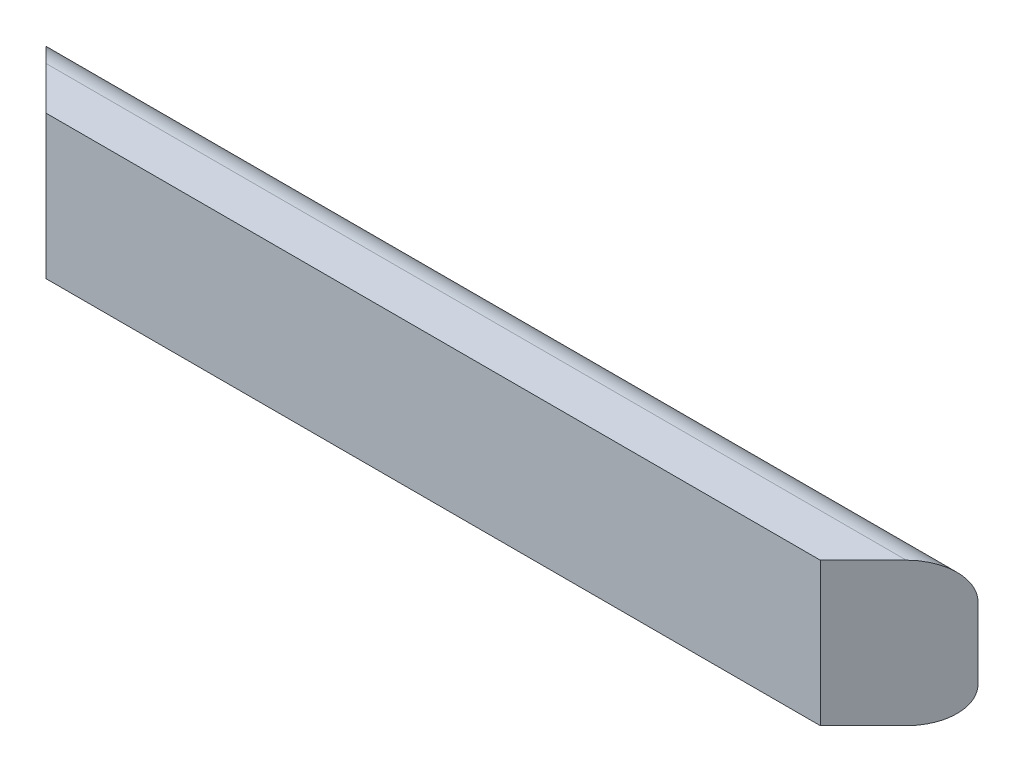
from build123d import *

# Parameters (mm, degrees)
BOSS_EXTRUDE1_DEPTH      = 412.75
BOSS_EXTRUDE1_DEPTH_BACK = 412.75
CUT_EXTRUDE1_DEPTH       = 438.459238101
BOSS_EXTRUDE2_DEPTH      = 0.254


with BuildPart() as part:
    # Sketch1 → Boss-Extrude1 (new, two sides: drawn at the far end of the back side and taken through both)
    with BuildSketch(Plane(origin=(0, 0, 0), x_dir=(0, 0, -1), z_dir=(1, 0, 0)).offset(-BOSS_EXTRUDE1_DEPTH_BACK)):
        with BuildLine():
            Line((6.35, 127), (38.1, 127))
            ThreePointArc((38.1, 127), (60.550640303, 117.700640303), (69.85, 95.25))
            Line((69.85, 95.25), (69.85, 31.75))
            ThreePointArc((69.85, 31.75), (60.550640303, 9.299359697), (38.1, 0))
            Line((38.1, 0), (6.35, 0))
            Line((6.35, 0), (0, 0))
            Line((0, 0), (0, 127))
            Line((0, 127), (6.35, 127))
        make_face()
    extrude(amount=BOSS_EXTRUDE1_DEPTH + BOSS_EXTRUDE1_DEPTH_BACK)

    # Sketch2 → Cut-Extrude1 (cut, through all)
    with BuildSketch(Plane(origin=(0, 127, 0), x_dir=(1, 0, 0), z_dir=(0, 1, 0))):
        Polygon((412.75, 69.85), (342.9, 0), (412.75, 0), align=None)
        Polygon((-412.75, 69.85), (-342.9, 0), (-412.75, 0), align=None)
    extrude(amount=-CUT_EXTRUDE1_DEPTH, mode=Mode.SUBTRACT)

    # Sketch3 → Boss-Extrude2 (add)
    # profile 1 of 4: a face of its own
    with BuildSketch(Plane(origin=(0, 0, -69.85), x_dir=(-1, 0, 0), z_dir=(0, 0, -1))):
        with BuildLine():
            Line((-141.487283737, 49.988561174), (-129.139597752, 51.506297576))
            add(Edge.make_bspline(
                [(-129.139597752, 51.506297576), (-129.032962671, 50.747064564), (-128.830554263, 49.305933343), (-128.199436765, 47.311224862), (-127.375544429, 45.575399002), (-126.284752313, 44.15314528), (-125.023613015, 43.021998512), (-123.617151139, 42.214884132), (-122.078088821, 41.705902447), (-121.006107171, 41.654466058), (-120.457631044, 41.628148788)],
                knots=[0, 0, 0, 0, 1.26631894, 2.403651751, 3.447242243, 4.428907923, 5.348362865, 6.231623936, 7.095215805, 8, 8, 8, 8], degree=3))
            add(Edge.make_bspline(
                [(-120.457631044, 41.628148788), (-120.161330426, 41.634511687), (-119.574405191, 41.647115596), (-118.711610093, 41.779355342), (-117.882599365, 41.996726001), (-117.095552411, 42.309506181), (-116.34671202, 42.698139812), (-115.626217183, 43.160949602), (-114.964334496, 43.738979779), (-114.318123207, 44.37140603), (-113.74466798, 45.091318713), (-113.239522217, 45.872393773), (-112.796104536, 46.706884108), (-112.452410387, 47.616306001), (-112.18337499, 48.58096015), (-111.991040418, 49.605033933), (-111.873985761, 50.684667137), (-111.859983423, 51.424537153), (-111.852837373, 51.802127553)],
                knots=[0, 0, 0, 0, 0.951760839, 1.885289532, 2.797832748, 3.70117291, 4.60103766, 5.506897018, 6.445598779, 7.420035506, 8.410036365, 9.396193293, 10.407074535, 11.440988179, 12.514285005, 13.622404236, 14.786601276, 16, 16, 16, 16], degree=3))
            add(Edge.make_bspline(
                [(-111.852837373, 51.802127553), (-111.879604371, 52.502912818), (-111.930665339, 53.839737143), (-112.325229706, 55.7363289), (-113.009474812, 57.403510016), (-113.968135732, 58.811372072), (-115.107297702, 59.943891395), (-116.38339385, 60.795183755), (-117.808484904, 61.284244815), (-118.799184723, 61.350799485), (-119.300035483, 61.384446364)],
                knots=[0, 0, 0, 0, 1.241512862, 2.368321189, 3.414110003, 4.41529485, 5.36642979, 6.245396713, 7.112955941, 8, 8, 8, 8], degree=3))
            add(Edge.make_bspline(
                [(-119.300035483, 61.384446364), (-119.656610092, 61.375322265), (-120.412510639, 61.355980138), (-121.58827301, 61.155013218), (-122.870446973, 60.877669799), (-123.74350999, 60.610883817), (-124.200523358, 60.471232088)],
                knots=[0, 0, 0, 0, 0.854525515, 1.811503923, 2.854410343, 4, 4, 4, 4], degree=3))
            Line((-124.200523358, 60.471232088), (-123.042927797, 70.439416087))
            add(Edge.make_bspline(
                [(-123.042927797, 70.439416087), (-122.699793823, 70.433529916), (-122.033943987, 70.422107829), (-121.061603486, 70.502723798), (-120.151462794, 70.649910548), (-119.305645566, 70.888720241), (-118.523364253, 71.178445171), (-117.797777169, 71.542462959), (-117.146635388, 71.995464307), (-116.353828061, 72.679267448), (-115.542714487, 73.703905506), (-114.809416499, 75.108914451), (-114.400837558, 76.710921704), (-114.349142899, 77.832955884), (-114.32237457, 78.413963285)],
                knots=[0, 0, 0, 0, 0.916749589, 1.778948191, 2.604102396, 3.376994206, 4.124053722, 4.831292757, 5.54010828, 6.238660037, 7.62386988, 9.002523041, 10.447858069, 12, 12, 12, 12], degree=3))
            add(Edge.make_bspline(
                [(-114.32237457, 78.413963285), (-114.340421784, 78.908707793), (-114.375026012, 79.857344611), (-114.685449372, 81.207210903), (-115.215277515, 82.398975794), (-115.956386082, 83.411952531), (-116.865477663, 84.234520651), (-117.928062929, 84.842338565), (-119.145149606, 85.196777383), (-120.000810014, 85.236190038), (-120.444768871, 85.256639269)],
                knots=[0, 0, 0, 0, 1.146968804, 2.199229744, 3.192297141, 4.153502289, 5.090509175, 6.0173182, 6.971286811, 8, 8, 8, 8], degree=3))
            add(Edge.make_bspline(
                [(-120.444768871, 85.256639269), (-120.889846441, 85.23463774), (-121.764714725, 85.191390357), (-123.016587755, 84.763605166), (-124.171507752, 84.101718979), (-125.190641675, 83.153836406), (-126.073947139, 81.974913825), (-126.758445098, 80.537127716), (-127.240501283, 78.863003816), (-127.406174904, 77.658066607), (-127.493239621, 77.024848612)],
                knots=[0, 0, 0, 0, 0.889956214, 1.749345552, 2.62404616, 3.543272128, 4.520224035, 5.562553653, 6.719074424, 8, 8, 8, 8], degree=3))
            Line((-127.493239621, 77.024848612), (-139.840925606, 78.87700151))
            add(Edge.make_bspline(
                [(-139.840925606, 78.87700151), (-139.637325698, 79.819720317), (-139.247589866, 81.624295295), (-138.451300452, 84.152640803), (-137.51697339, 86.384586473), (-136.425350386, 88.345144228), (-135.132300003, 90.068833733), (-133.597053466, 91.56499453), (-131.842580673, 92.877041648), (-129.872231734, 93.976422082), (-127.72989182, 94.857582736), (-125.449924009, 95.509752612), (-123.038143208, 95.883504452), (-121.389271871, 95.93280399), (-120.547666254, 95.957967122)],
                knots=[0, 0, 0, 0, 1.220808349, 2.336900656, 3.3513467, 4.279992853, 5.171472476, 6.069835959, 6.985198729, 7.938095762, 8.919113729, 9.91246339, 10.934493858, 12, 12, 12, 12], degree=3))
            add(Edge.make_bspline(
                [(-120.547666254, 95.957967122), (-119.826495707, 95.941556837), (-118.417458275, 95.909494092), (-116.362747759, 95.633600563), (-114.418641852, 95.185408458), (-112.582430461, 94.55140964), (-110.845601518, 93.744182635), (-109.237149801, 92.728555989), (-107.723332756, 91.556250599), (-106.826681472, 90.643909975), (-106.373551717, 90.18285149)],
                knots=[0, 0, 0, 0, 1.096978699, 2.143298912, 3.148181587, 4.128190255, 5.094201205, 6.055441919, 7.017302331, 8, 8, 8, 8], degree=3))
            add(Edge.make_bspline(
                [(-106.373551717, 90.18285149), (-106.023537684, 89.789960912), (-105.332223658, 89.013961265), (-104.434645502, 87.76983024), (-103.683420883, 86.477065821), (-103.046188148, 85.162642075), (-102.572302428, 83.796078916), (-102.21901684, 82.398827932), (-102.009177681, 80.958508612), (-101.986217703, 79.983817154), (-101.974688585, 79.494385809)],
                knots=[0, 0, 0, 0, 1.065582675, 2.104636323, 3.101288825, 4.092056841, 5.059084899, 6.026073946, 7.008813224, 8, 8, 8, 8], degree=3))
            add(Edge.make_bspline(
                [(-101.974688585, 79.494385809), (-101.999837567, 78.805967701), (-102.049410836, 77.448969012), (-102.504305984, 75.474938782), (-103.235446067, 73.608860109), (-104.24640348, 71.843604558), (-105.564457117, 70.195553035), (-107.18702939, 68.679534469), (-109.066442264, 67.237696856), (-110.47902046, 66.423262632), (-111.209728728, 66.001966436)],
                knots=[0, 0, 0, 0, 0.957571776, 1.887550067, 2.804499428, 3.740591036, 4.709432777, 5.731457079, 6.826512349, 8, 8, 8, 8], degree=3))
            add(Edge.make_bspline(
                [(-111.209728728, 66.001966436), (-110.774920169, 65.897167744), (-109.916890308, 65.690363151), (-108.677362831, 65.268754117), (-107.51653992, 64.727943501), (-106.405990923, 64.133720127), (-105.373275352, 63.429091991), (-104.398375528, 62.648317715), (-103.518575507, 61.746303626), (-102.675530041, 60.793323049), (-101.938600577, 59.747465525), (-101.272737218, 58.65913874), (-100.737902273, 57.501788739), (-100.280457077, 56.30517302), (-99.939604466, 55.04995027), (-99.672693466, 53.745511556), (-99.538908832, 52.383737677), (-99.516490646, 51.459364418), (-99.505151388, 50.99181066)],
                knots=[0, 0, 0, 0, 1.037381978, 2.047118658, 3.030848314, 4.005687143, 4.965748246, 5.927353932, 6.897971669, 7.885165084, 8.876109723, 9.862099733, 10.840989857, 11.829385213, 12.830906716, 13.855042526, 14.915067134, 16, 16, 16, 16], degree=3))
            add(Edge.make_bspline(
                [(-99.505151388, 50.99181066), (-99.51956021, 50.308923997), (-99.547976345, 48.962179679), (-99.860092867, 46.985641935), (-100.33429342, 45.08605931), (-100.987783847, 43.255757597), (-101.861740077, 41.517130623), (-102.906804937, 39.845787022), (-104.151443825, 38.258375189), (-105.570731672, 36.76692481), (-107.12155314, 35.401826739), (-108.787905722, 34.20277421), (-110.545100916, 33.187927397), (-112.403207023, 32.358101162), (-114.346066599, 31.712439867), (-116.390404873, 31.268680945), (-118.519638929, 30.972625251), (-119.976421673, 30.942228997), (-120.714874502, 30.926820934)],
                knots=[0, 0, 0, 0, 1.006520189, 1.984993146, 2.943645202, 3.891894145, 4.845023195, 5.808336607, 6.795092628, 7.815033679, 8.841288157, 9.838185905, 10.83832808, 11.829129029, 12.835072876, 13.85234392, 14.911338897, 16, 16, 16, 16], degree=3))
            add(Edge.make_bspline(
                [(-120.714874502, 30.926820934), (-121.414664815, 30.938552975), (-122.789217771, 30.961597466), (-124.80144877, 31.234596831), (-126.728716817, 31.636211012), (-128.559772747, 32.223729356), (-130.310566514, 32.947387314), (-131.948052536, 33.880254279), (-133.514382161, 34.940534945), (-134.958381911, 36.182569084), (-136.300989349, 37.536259204), (-137.480309186, 39.024940262), (-138.531240362, 40.601098684), (-139.435141753, 42.278708256), (-140.184438628, 44.062128348), (-140.767869909, 45.946755571), (-141.23316759, 47.926818682), (-141.401411105, 49.29184333), (-141.487283737, 49.988561174)],
                knots=[0, 0, 0, 0, 1.077528213, 2.11651914, 3.123276654, 4.10732375, 5.075386463, 6.036572488, 7.005896639, 7.98540975, 8.966414275, 9.939311093, 10.906719916, 11.882103104, 12.870994428, 13.882228509, 14.919075059, 16, 16, 16, 16], degree=3))
        make_face()
    # profile 2 of 4: a face of its own
    with BuildSketch(Plane(origin=(0, 0, -69.85), x_dir=(-1, 0, 0), z_dir=(0, 0, -1))):
        with BuildLine():
            Line((-62.462093433, 50.117182903), (-51.760765579, 51.506297576))
            add(Edge.make_bspline(
                [(-51.760765579, 51.506297576), (-51.642380093, 50.780568), (-51.41440933, 49.383056103), (-50.706719158, 47.432022129), (-49.721163459, 45.713239113), (-48.454544685, 44.265955932), (-47.012973527, 43.088892136), (-45.420400197, 42.249747655), (-43.725063478, 41.721422366), (-42.550922605, 41.659383078), (-41.959789828, 41.628148788)],
                knots=[0, 0, 0, 0, 1.154848647, 2.223851388, 3.245409892, 4.254330626, 5.232966172, 6.156270698, 7.071756339, 8, 8, 8, 8], degree=3))
            add(Edge.make_bspline(
                [(-41.959789828, 41.628148788), (-41.616370664, 41.634182289), (-40.944122367, 41.645992961), (-39.953467627, 41.780059227), (-39.007120064, 41.997870012), (-38.096125975, 42.293479709), (-37.229973938, 42.682269208), (-36.407893848, 43.158045805), (-35.626813523, 43.721477925), (-34.8827795, 44.358572654), (-34.195286077, 45.085965129), (-33.620713178, 45.923247733), (-33.111714207, 46.827631979), (-32.697063985, 47.823687055), (-32.398158929, 48.914903645), (-32.160358427, 50.082600806), (-32.039139227, 51.340876348), (-32.016273212, 52.204936271), (-32.004468003, 52.651030964)],
                knots=[0, 0, 0, 0, 0.981268084, 1.920847364, 2.851509818, 3.754644372, 4.654445699, 5.560569672, 6.465366234, 7.403985617, 8.358004942, 9.316972086, 10.299158387, 11.321223707, 12.392031981, 13.529051644, 14.724304971, 16, 16, 16, 16], degree=3))
            add(Edge.make_bspline(
                [(-32.004468003, 52.651030964), (-32.011143045, 53.071527767), (-32.024043665, 53.884207159), (-32.14373122, 55.061642393), (-32.327450959, 56.161966499), (-32.619720064, 57.177134497), (-32.953514389, 58.126018474), (-33.403553287, 58.974986748), (-33.897360682, 59.760920289), (-34.499236907, 60.441413996), (-35.155036013, 61.04267379), (-35.85345981, 61.578386386), (-36.602348538, 62.02538699), (-37.394245331, 62.409044411), (-38.242877677, 62.688498613), (-39.141362088, 62.874418229), (-40.077617441, 63.013987895), (-40.72018881, 63.025139942), (-41.046575552, 63.030804496)],
                knots=[0, 0, 0, 0, 1.29221626, 2.497420946, 3.635005972, 4.715822244, 5.741640361, 6.720139245, 7.663294346, 8.588224307, 9.502291809, 10.395891443, 11.288713187, 12.178904539, 13.095818132, 14.026458458, 14.997562253, 16, 16, 16, 16], degree=3))
            add(Edge.make_bspline(
                [(-41.046575552, 63.030804496), (-41.45922931, 63.016010253), (-42.282480026, 62.986495507), (-43.497746027, 62.746569399), (-44.680614197, 62.355968027), (-45.829855089, 61.812223729), (-46.94242819, 61.110991483), (-48.013516609, 60.24994579), (-49.061506146, 59.243900895), (-49.705242128, 58.483757088), (-50.03723441, 58.091730101)],
                knots=[0, 0, 0, 0, 0.931687088, 1.85873035, 2.786835662, 3.740075265, 4.723687035, 5.750832598, 6.840042753, 8, 8, 8, 8], degree=3))
            Line((-50.03723441, 58.091730101), (-60.815735301, 59.609466504))
            Line((-60.815735301, 59.609466504), (-53.40712371, 95.134788057))
            Line((-53.40712371, 95.134788057), (-22.126319215, 95.134788057))
            Line((-22.126319215, 95.134788057), (-22.126319215, 82.787102072))
            Line((-22.126319215, 82.787102072), (-43.503250577, 82.787102072))
            Line((-43.503250577, 82.787102072), (-46.024236465, 71.326906017))
            add(Edge.make_bspline(
                [(-46.024236465, 71.326906017), (-45.381816964, 71.697561885), (-44.130764923, 72.419379607), (-42.133452016, 73.162424748), (-40.125878911, 73.639323084), (-38.77255902, 73.701356019), (-38.101137958, 73.732132349)],
                knots=[0, 0, 0, 0, 1.060051984, 2.064352337, 3.039669322, 4, 4, 4, 4], degree=3))
            add(Edge.make_bspline(
                [(-38.101137958, 73.732132349), (-37.469945095, 73.715146712), (-36.223094674, 73.681593499), (-34.394484466, 73.406300074), (-32.640499622, 72.952588242), (-30.955217357, 72.321200736), (-29.350691977, 71.493616454), (-27.813091414, 70.49335495), (-26.36461393, 69.303058942), (-24.989696213, 67.957093414), (-23.73586773, 66.467944448), (-22.653087096, 64.844102956), (-21.717878139, 63.126012929), (-20.956507189, 61.294691655), (-20.383173048, 59.347591366), (-19.953801197, 57.301478184), (-19.713270125, 55.1434317), (-19.675867936, 53.671994501), (-19.656782018, 52.921136595)],
                knots=[0, 0, 0, 0, 0.974409932, 1.924837087, 2.848242317, 3.768103797, 4.697919751, 5.630842317, 6.595644344, 7.588240789, 8.59876155, 9.595918743, 10.597287627, 11.615415169, 12.652315553, 13.727511434, 14.840374562, 16, 16, 16, 16], degree=3))
            add(Edge.make_bspline(
                [(-19.656782018, 52.921136595), (-19.674008435, 52.290478014), (-19.70819943, 51.038746756), (-19.908190569, 49.186441287), (-20.281535625, 47.38868729), (-20.757123097, 45.635357275), (-21.414391177, 43.941141258), (-22.194366108, 42.294994206), (-23.126749606, 40.699872055), (-23.846097598, 39.693450362), (-24.209991225, 39.184335937)],
                knots=[0, 0, 0, 0, 1.027524957, 2.039431707, 3.02972907, 4.015954419, 4.995255842, 5.985553205, 6.980960039, 8, 8, 8, 8], degree=3))
            add(Edge.make_bspline(
                [(-24.209991225, 39.184335937), (-24.740475206, 38.528772068), (-25.784529389, 37.238546115), (-27.571811387, 35.542219666), (-29.515699496, 34.11760187), (-31.610928766, 32.947630365), (-33.855267088, 32.029523153), (-36.258840659, 31.391212776), (-38.804026141, 30.996298985), (-40.552052993, 30.950317625), (-41.445302912, 30.926820934)],
                knots=[0, 0, 0, 0, 1.018121711, 2.003781959, 2.967346956, 3.92281574, 4.896313303, 5.889026666, 6.921282725, 8, 8, 8, 8], degree=3))
            add(Edge.make_bspline(
                [(-41.445302912, 30.926820934), (-42.166315783, 30.939844326), (-43.574132764, 30.965273209), (-45.635849187, 31.216745865), (-47.589676133, 31.625295782), (-49.447940052, 32.192240734), (-51.199607305, 32.928566139), (-52.858287962, 33.817543442), (-54.410162381, 34.878876743), (-55.848084307, 36.104548031), (-57.16849389, 37.459270233), (-58.346241116, 38.941581824), (-59.394127645, 40.526691501), (-60.292161634, 42.230616097), (-61.057498838, 44.041405853), (-61.66689253, 45.968341085), (-62.168636561, 47.998571276), (-62.363191729, 49.403162141), (-62.462093433, 50.117182903)],
                knots=[0, 0, 0, 0, 1.098912142, 2.145685936, 3.161086862, 4.139124218, 5.10307886, 6.053641493, 7.003731987, 7.963777669, 8.929946266, 9.883471279, 10.846206077, 11.822909928, 12.81603559, 13.839338588, 14.901632394, 16, 16, 16, 16], degree=3))
        make_face()
    # profile 3 of 4: a face of its own
    with BuildSketch(Plane(origin=(0, 0, -69.85), x_dir=(-1, 0, 0), z_dir=(0, 0, -1))):
        with BuildLine():
            Line((18.209455003, 47.673370052), (30.557140988, 49.036760379))
            add(Edge.make_bspline(
                [(30.557140988, 49.036760379), (30.637994326, 48.445590088), (30.790823737, 47.328156849), (31.279511065, 45.794795533), (31.892008924, 44.478581747), (32.724355074, 43.419388765), (33.717669119, 42.610927467), (34.855326057, 42.027551658), (36.141865973, 41.691510589), (37.046257906, 41.649795905), (37.515576528, 41.628148788)],
                knots=[0, 0, 0, 0, 1.261142327, 2.383817955, 3.394783384, 4.319218401, 5.209639591, 6.086630953, 7.00709008, 8, 8, 8, 8], degree=3))
            add(Edge.make_bspline(
                [(37.515576528, 41.628148788), (37.82108926, 41.635229881), (38.424869783, 41.649224147), (39.308127474, 41.846519093), (40.162847532, 42.123113217), (40.980220047, 42.527938781), (41.752430951, 43.048944096), (42.49862858, 43.674368665), (43.195924432, 44.424262543), (43.888543524, 45.285004598), (44.515475303, 46.342388481), (45.068777974, 47.624884025), (45.585382265, 49.132135662), (46.00974389, 50.882888201), (46.391709615, 52.862052998), (46.723999497, 55.075963918), (46.993591195, 57.525973704), (47.112747025, 59.240222456), (47.175068376, 60.136815593)],
                knots=[0, 0, 0, 0, 0.636702566, 1.258306339, 1.881198412, 2.509855161, 3.155497192, 3.822694, 4.538353708, 5.290656154, 6.125969777, 7.095962945, 8.203044623, 9.449504243, 10.854253673, 12.411741228, 14.12325476, 16, 16, 16, 16], degree=3))
            add(Edge.make_bspline(
                [(47.175068376, 60.136815593), (46.780053355, 59.712840793), (46.001223909, 58.87691294), (44.71130418, 57.780208753), (43.337872185, 56.858167302), (41.887954292, 56.114969452), (40.376676573, 55.507774121), (38.779192363, 55.108371957), (37.117744626, 54.834342387), (35.981841775, 54.810896119), (35.406180172, 54.799013839)],
                knots=[0, 0, 0, 0, 1.041520616, 2.053509057, 3.037255372, 4.009786987, 4.979165048, 5.959157055, 6.965725879, 8, 8, 8, 8], degree=3))
            add(Edge.make_bspline(
                [(35.406180172, 54.799013839), (34.775120953, 54.817112148), (33.529147227, 54.852845749), (31.696139942, 55.112365051), (29.930031823, 55.554910939), (28.228003244, 56.168602168), (26.598658471, 56.982018065), (25.021221497, 57.94101676), (23.529542388, 59.101824931), (22.101856176, 60.398882812), (20.817953708, 61.859092441), (19.671322158, 63.424836719), (18.701040457, 65.104727317), (17.91842378, 66.896978746), (17.313156595, 68.790183052), (16.873104289, 70.782750287), (16.615986189, 72.885063224), (16.580967533, 74.323086545), (16.563096872, 75.056936158)],
                knots=[0, 0, 0, 0, 0.980269742, 1.935460739, 2.869230488, 3.804804075, 4.740187949, 5.694100724, 6.667990488, 7.67211685, 8.68661751, 9.683203946, 10.682901945, 11.694007529, 12.71565541, 13.766145059, 14.860022949, 16, 16, 16, 16], degree=3))
            add(Edge.make_bspline(
                [(16.563096872, 75.056936158), (16.579358734, 75.820994235), (16.611257549, 77.319749302), (16.891105872, 79.504796869), (17.318494615, 81.584769941), (17.956662218, 83.541236382), (18.750769394, 85.39520876), (19.737778026, 87.123436928), (20.884990955, 88.74995874), (22.225559796, 90.226408206), (23.682781679, 91.577954163), (25.254774523, 92.754100647), (26.932418562, 93.73702521), (28.700850793, 94.55387073), (30.573337417, 95.182961466), (32.537911021, 95.631263772), (34.596481997, 95.909234714), (36.001235713, 95.941500809), (36.718121808, 95.957967122)],
                knots=[0, 0, 0, 0, 1.1238417, 2.204496613, 3.236450213, 4.243990082, 5.227299393, 6.199188572, 7.167261658, 8.150145869, 9.127934804, 10.088143708, 11.032722787, 11.984040773, 12.949643861, 13.93368149, 14.945498424, 16, 16, 16, 16], degree=3))
            add(Edge.make_bspline(
                [(36.718121808, 95.957967122), (37.499663885, 95.936372471), (39.032175865, 95.894027903), (41.278242682, 95.541418364), (43.409401552, 94.941490996), (45.446828539, 94.136998461), (47.361156623, 93.065217924), (49.177290656, 91.771676373), (50.87096538, 90.229965387), (52.471833872, 88.470616193), (53.928355727, 86.437701122), (55.168440749, 84.088178395), (56.223269366, 81.444294852), (57.074690413, 78.500372651), (57.739976139, 75.2571666), (58.199148351, 71.714739072), (58.506399323, 67.872388312), (58.531967639, 65.209451336), (58.545229221, 63.828259215)],
                knots=[0, 0, 0, 0, 0.854852685, 1.67626545, 2.479841517, 3.273455256, 4.067207639, 4.874322592, 5.708061326, 6.568303409, 7.473035808, 8.43640186, 9.467839227, 10.582672616, 11.785182758, 13.086903962, 14.489057258, 16, 16, 16, 16], degree=3))
            add(Edge.make_bspline(
                [(58.545229221, 63.828259215), (58.52606159, 62.42569891), (58.489028928, 59.715893942), (58.190226205, 55.803928156), (57.717275991, 52.191835176), (57.021911158, 48.886068819), (56.149275747, 45.874742553), (55.051986756, 43.169327234), (53.774007676, 40.755869999), (52.277963864, 38.656593307), (50.633270353, 36.832085623), (48.865538969, 35.251440658), (46.97223569, 33.919424772), (44.969790555, 32.808349363), (42.828262634, 31.976311202), (40.577286451, 31.373516087), (38.210806803, 30.983032523), (36.59105741, 30.945785963), (35.766321013, 30.926820934)],
                knots=[0, 0, 0, 0, 1.487495966, 2.873904204, 4.158892752, 5.348685137, 6.453750751, 7.479786756, 8.440129076, 9.343583348, 10.206541379, 11.040779453, 11.853317241, 12.65721927, 13.463689683, 14.283322899, 15.125910407, 16, 16, 16, 16], degree=3))
            add(Edge.make_bspline(
                [(35.766321013, 30.926820934), (35.174171393, 30.939007153), (34.012346265, 30.962917083), (32.311353086, 31.155274015), (30.697323837, 31.489528146), (29.175630778, 31.956331344), (27.734397737, 32.530354721), (26.385860646, 33.258599195), (25.129668142, 34.124419027), (23.944430126, 35.101203305), (22.877760377, 36.233459151), (21.896551154, 37.483552941), (21.0163417, 38.863993528), (20.266693516, 40.386646363), (19.574694261, 42.016187918), (19.017259722, 43.788735665), (18.552348211, 45.684288067), (18.325771266, 46.998633491), (18.209455003, 47.673370052)],
                knots=[0, 0, 0, 0, 1.056675019, 2.073245589, 3.050223185, 3.994251036, 4.910773036, 5.814621688, 6.723026041, 7.630269412, 8.550362125, 9.493303905, 10.463425011, 11.466105649, 12.519144845, 13.620215273, 14.778306119, 16, 16, 16, 16], degree=3))
        make_face()
        with BuildLine():
            add(Edge.make_bspline(
                [(46.197543236, 74.748244008), (46.192995259, 75.156048345), (46.184156267, 75.94861615), (46.033839982, 77.096390923), (45.815742371, 78.171216494), (45.526890624, 79.185016488), (45.123602986, 80.121029748), (44.645261082, 80.993995513), (44.080043896, 81.796913755), (43.209927358, 82.734897139), (42.028819488, 83.744543753), (40.446606524, 84.62152998), (38.74720594, 85.168334822), (37.571066842, 85.226950878), (36.975365266, 85.256639269)],
                knots=[0, 0, 0, 0, 0.937516427, 1.822063352, 2.657744432, 3.45986214, 4.242145632, 4.997087526, 5.746986504, 6.494090859, 7.936347984, 9.300605415, 10.632786197, 12, 12, 12, 12], degree=3))
            add(Edge.make_bspline(
                [(36.975365266, 85.256639269), (36.419313856, 85.23142671), (35.337020127, 85.1823532), (33.788021298, 84.74130182), (32.38478746, 84.025462088), (31.362675998, 83.19033878), (30.634271685, 82.393802965), (30.177740451, 81.680286507), (29.789011167, 80.884969938), (29.467172874, 80.001072357), (29.213222033, 79.028114768), (29.03316865, 77.960908116), (28.935156065, 76.808046526), (28.919070985, 76.008914616), (28.910782857, 75.59714742)],
                knots=[0, 0, 0, 0, 1.397188569, 2.719475933, 4.017809812, 5.337496372, 6.01771949, 6.727108146, 7.460709441, 8.242571956, 9.09066939, 9.98839818, 10.963485712, 12, 12, 12, 12], degree=3))
            add(Edge.make_bspline(
                [(28.910782857, 75.59714742), (28.917415948, 75.176645173), (28.93023549, 74.363955259), (29.050489251, 73.186593506), (29.230890108, 72.094168937), (29.523932708, 71.095211047), (29.868235556, 70.175499084), (30.284003604, 69.332237197), (30.811986655, 68.596575836), (31.574683025, 67.724000391), (32.690543429, 66.835776981), (34.203521379, 66.061288394), (35.874923032, 65.582484293), (37.045062605, 65.528157919), (37.644198257, 65.500341693)],
                knots=[0, 0, 0, 0, 1.000122719, 1.932902026, 2.813346472, 3.630219284, 4.405058741, 5.14865055, 5.858963796, 6.55275156, 7.902081098, 9.220520156, 10.576848858, 12, 12, 12, 12], degree=3))
            add(Edge.make_bspline(
                [(37.644198257, 65.500341693), (38.226442431, 65.523155771), (39.36254862, 65.56767183), (40.978917558, 66.043138479), (42.462749954, 66.772451151), (43.548341231, 67.63319606), (44.3244001, 68.448453183), (44.823887088, 69.148575122), (45.25448236, 69.914845239), (45.59835283, 70.754069815), (45.868798685, 71.658960459), (46.05923458, 72.628038663), (46.177505057, 73.664886876), (46.190717154, 74.379194287), (46.197543236, 74.748244008)],
                knots=[0, 0, 0, 0, 1.470045212, 2.868431389, 4.227473852, 5.634383908, 6.348475288, 7.071419378, 7.805118666, 8.569021284, 9.362200428, 10.192314795, 11.06605236, 12, 12, 12, 12], degree=3))
        make_face(mode=Mode.SUBTRACT)
    # profile 4 of 4: a face of its own
    with BuildSketch(Plane(origin=(0, 0, -69.85), x_dir=(-1, 0, 0), z_dir=(0, 0, -1))):
        with BuildLine():
            Line((95.588287176, 82.787102072), (95.588287176, 95.134788057))
            Line((95.588287176, 95.134788057), (137.570419525, 95.134788057))
            Line((137.570419525, 95.134788057), (137.570419525, 86.079818334))
            add(Edge.make_bspline(
                [(137.570419525, 86.079818334), (137.132466652, 85.634215576), (136.232161359, 84.718184318), (134.942562083, 83.219008064), (133.633855634, 81.592138761), (132.333408388, 79.815654384), (131.000796599, 77.917617609), (129.694583854, 75.861644239), (128.369791871, 73.674406405), (126.586203006, 70.580554119), (124.501410169, 66.539027103), (122.295809638, 61.515202589), (120.416738972, 56.337091808), (119.130033868, 51.924959688), (118.260657453, 48.388642584), (117.692648976, 45.8028037), (117.214506378, 43.289733693), (116.825537694, 40.845015906), (116.535239413, 38.467535056), (116.30585427, 36.165556823), (116.192685302, 33.933467795), (116.175986043, 32.470381045), (116.167763818, 31.75)],
                knots=[0, 0, 0, 0, 0.628545797, 1.29210959, 1.98878689, 2.729126096, 3.507039704, 4.322017351, 5.179550397, 6.080149501, 7.915136253, 9.752312618, 11.597470118, 13.454141581, 14.373891568, 15.261584755, 16.117868869, 16.947726723, 17.752002974, 18.527724242, 19.275094557, 20, 20, 20, 20], degree=3))
            Line((116.167763818, 31.75), (103.820077833, 31.75))
            add(Edge.make_bspline(
                [(103.820077833, 31.75), (103.861365707, 32.843859978), (103.944400134, 35.043731895), (104.255069304, 38.345667879), (104.743008648, 41.659898836), (105.349062065, 44.994084575), (106.149203658, 48.340108138), (107.062410362, 51.71036421), (108.168622974, 55.086852328), (109.408657623, 58.463116455), (110.777590695, 61.80710167), (112.26953513, 65.077331726), (113.880634103, 68.253404415), (115.589935593, 71.3464789), (117.417324861, 74.34660455), (119.36417774, 77.250523525), (121.402878607, 80.079241784), (122.860574051, 81.884634059), (123.589237582, 82.787102072)],
                knots=[0, 0, 0, 0, 0.943249748, 1.896978291, 2.856365892, 3.829648507, 4.816416106, 5.820376826, 6.838120354, 7.877341886, 8.919613352, 9.951365796, 10.974227495, 11.988073359, 12.996274698, 14.000568529, 15.000536908, 16, 16, 16, 16], degree=3))
            Line((123.589237582, 82.787102072), (95.588287176, 82.787102072))
        make_face()
    extrude(amount=BOSS_EXTRUDE2_DEPTH)


solid = part.part
